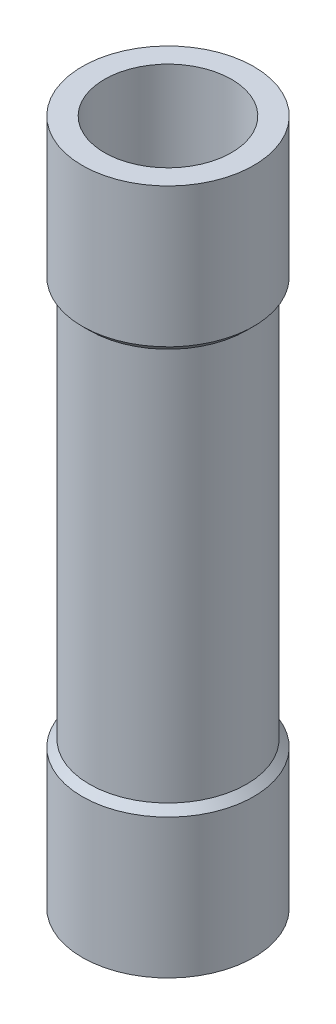
from build123d import *

# Parameters (mm, degrees)
SKETCH1_W = 1.143
SKETCH1_H = 14.478


with BuildPart() as part:
    # Sketch1 → Revolve1 (revolve)
    with BuildSketch(Plane.XY):
        Polygon((2.259, 12.192), (2.259, -12.192), (3.048, -12.192), (3.048, -7.239), (2.794, -6.985), (2.794, 6.985), (3.048, 7.239), (3.048, 12.192), align=None)
        with Locations((1.5875, 0)):
            Rectangle(SKETCH1_W, SKETCH1_H)
    revolve(axis=Axis((0, 0, 0), (0, 1, 0)))


solid = part.part
